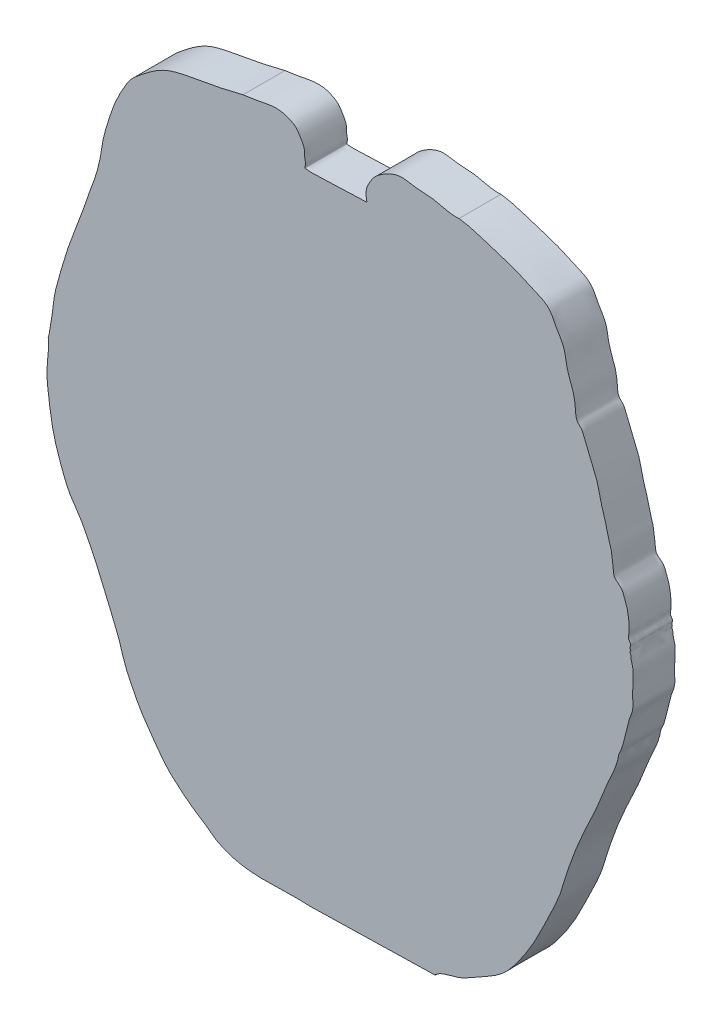
from build123d import *

# Parameters (mm, degrees)
BOSS_EXTRUDE1_DEPTH = 100


with BuildPart() as part:
    # faceplate → Boss-Extrude1 (new body)
    with BuildSketch(Plane.XY):
        with BuildLine():
            Line((-544.994463337, -612.515143976), (-544.994463337, -613.515143976))
            Line((-544.994463337, -613.515143976), (-843.994463337, -620.515143976))
            add(Edge.make_bspline(
                [(-1067.80244218, -595.323122819), (-997.118302993, -634.980800497), (-919.007086082, -615.388320094), (-843.994463337, -620.515143976)],
                knots=[0, 0, 0, 0, 1, 1, 1, 1], degree=3))
            add(Edge.make_bspline(
                [(-1067.80244218, -595.323122819), (-1086.847009226, -579.729961904), (-1119.970174816, -561.224126278), (-1156.034719167, -531.360825002), (-1179.138150383, -511.221675605), (-1196.315966942, -490.961554628), (-1213.217398231, -467.461049471), (-1232.397649452, -440.899738497), (-1252.443193652, -410.675686141), (-1269.172612691, -376.572973765), (-1286.514519484, -341.087093501), (-1296.738650953, -301.232376709), (-1313.455916177, -261.143197942), (-1331.041833976, -218.738871303), (-1349.710417714, -174.628391124), (-1370.426950686, -132.166188439), (-1390.701638967, -90.573799688), (-1419.135356979, -54.815891576), (-1435.370486427, -11.470106108), (-1451.768411171, 32.502484745), (-1461.464593921, 79.097443036), (-1467.240520327, 123.638045122), (-1472.384850807, 165.299163162), (-1468.827354686, 202.626831232), (-1466.138049197, 228.429338434), (-1468.2675659, 242.799904931), (-1465.753983266, 248.150925961), (-1464.413789059, 264.200956181), (-1457.615160207, 293.619534204), (-1454.39758417, 337.845564286), (-1438.875880143, 390.748756206), (-1421.192254415, 453.45936783), (-1394.593685546, 518.904193396), (-1375.922839318, 572.231050768), (-1364.069654655, 607.904754904), (-1355.21841365, 628.932491538), (-1349.178109577, 652.608037387), (-1341.652426333, 681.82767433), (-1338.216580607, 716.565441158), (-1327.985576082, 750.106761733), (-1318.017985391, 782.616202465), (-1306.487970813, 813.178643601), (-1292.835449403, 838.709685584), (-1281.186260324, 860.58493493), (-1266.214251902, 880.055386428), (-1236.139476743, 903.56594924), (-1193.192750352, 937.054053735), (-1128.986921291, 949.723978925), (-1077.595251561, 959.023790995), (-1036.017770222, 967.035879578), (-1015.134884478, 973.200541716), (-1003.321346267, 975.57699758)],
                knots=[0, 0, 0, 0, 0.038400577, 0.058895535, 0.073102163, 0.086227031, 0.100287806, 0.118344898, 0.137451121, 0.156851737, 0.177684982, 0.198987409, 0.220891405, 0.245488757, 0.270769139, 0.295710043, 0.319371077, 0.342894453, 0.366423959, 0.391141623, 0.416291007, 0.440510581, 0.46142581, 0.481689057, 0.498630439, 0.502576848, 0.503311323, 0.507792421, 0.527347312, 0.55072337, 0.576659082, 0.613250724, 0.652561818, 0.686915235, 0.701564699, 0.711304434, 0.722509605, 0.739687874, 0.75842357, 0.776832233, 0.794317236, 0.81162249, 0.827752702, 0.839523462, 0.850339049, 0.865807231, 0.8990697, 0.933921409, 0.965998955, 0.981184923, 1, 1, 1, 1], degree=3))
            add(Edge.make_bspline(
                [(-1003.321346267, 975.57699758), (-987.625286887, 977.252933347), (-962.704341777, 982.153446744), (-930.107996089, 988.286600947), (-907.73342782, 986.847160199), (-890.506709849, 980.153836056), (-877.228125332, 972.882171329), (-868.657722365, 960.200996549), (-862.567954839, 949.919049802), (-857.650273693, 940.261982009), (-856.6504648, 932.113160778), (-856.858442051, 925.892378776), (-856.484148597, 920.051139945), (-854.99962702, 913.576766741), (-853.805195867, 906.771565928), (-856.891801948, 896.179933995), (-849.532852724, 897.800494321), (-844.301174531, 896.09886282), (-836.051338893, 896.664214645), (-824.3827293, 897.356086054), (-811.091645754, 897.398998525), (-771.65856362, 898.71200455), (-737.566058229, 900.231134168), (-707.961414353, 901.352522194)],
                knots=[0, 0, 0, 0, 0.13240841, 0.213689757, 0.278435216, 0.316912048, 0.369102621, 0.401753187, 0.4437325, 0.470308429, 0.491738561, 0.51185491, 0.522604246, 0.541061714, 0.565961939, 0.589189548, 0.600387477, 0.616595683, 0.637287508, 0.668004499, 0.715727349, 0.748605259, 1, 1, 1, 1], degree=3))
            Line((-707.961414353, 901.352522194), (-709.994463337, 914.484856024))
            add(Edge.make_bspline(
                [(-709.994463337, 914.484856024), (-710.025141677, 928.111294219), (-706.556524679, 936.469765177), (-693.357896775, 960.709928189), (-674.711163852, 975.882524791), (-653.069107275, 988.272371826), (-626.361572185, 997.152418106), (-592.838906392, 988.511952991), (-545.459079884, 990.015587365), (-510.6758664, 975.288933631), (-488.174265844, 977.704076621)],
                knots=[0, 0, 0, 0, 0.092656003, 0.183249979, 0.277762299, 0.368010184, 0.465335235, 0.58698607, 0.749779645, 1, 1, 1, 1], degree=3))
            add(Edge.make_bspline(
                [(-488.174265844, 977.704076621), (-456.276698424, 973.772819568), (-413.082050902, 956.00139334), (-352.880537776, 940.042979017), (-315.670408772, 920.096845698), (-282.638450263, 909.115656445), (-266.103267679, 889.15808379), (-255.626909848, 864.830458522), (-234.906704646, 837.488931338), (-232.912182322, 797.596000168), (-216.805122627, 762.645190054), (-210.051739344, 729.655910292), (-210.486834721, 699.650404741), (-195.47336716, 689.870798641), (-190.356917308, 675.569305079), (-183.236172501, 660.113219275), (-175.670732081, 641.069479697), (-169.301082892, 624.944272331), (-160.940778667, 606.918509189), (-155.220160251, 586.954996915), (-150.771527302, 563.520719903), (-144.526324466, 542.958930792), (-137.322376345, 520.688253705), (-133.49244601, 498.072411215), (-124.168210293, 475.495115448), (-123.593395619, 456.007770617), (-119.600202312, 438.315780586), (-120.677701477, 423.113128801), (-108.963827659, 414.077110512), (-99.428314275, 406.758279523), (-95.092306104, 394.959107279), (-90.692706124, 383.673283845), (-86.96803427, 372.644834332), (-85.029413703, 361.089359505), (-83.067579223, 348.960606193), (-83.132833363, 337.646119686), (-81.40467488, 324.462048367), (-87.135516072, 311.967656037), (-77.007528945, 302.896484143), (-81.451175559, 296.340032763), (-78.992292255, 290.912569241), (-81.124845036, 285.38267309), (-77.850959558, 280.39504072), (-78.282792033, 272.538915116), (-75.694943087, 264.142711363), (-72.899133528, 253.136627469), (-73.345603979, 242.437648975), (-72.936069744, 230.51918813), (-74.257877633, 218.89550788), (-73.673619291, 207.232098077), (-74.800435642, 194.066808289), (-72.671127502, 179.444613631), (-75.293615575, 163.050653013), (-81.880933058, 149.176288447), (-87.222890375, 126.097374785), (-93.804330664, 101.137095727), (-100.061347869, 75.162630822), (-107.882675618, 61.861927769), (-108.797051733, 51.713845954), (-111.518705333, 42.34242457), (-115.227974273, 30.390584041), (-120.928179416, 16.556405837), (-131.70451367, -4.955944936), (-143.438372488, -34.31166144), (-156.513526554, -68.934431811), (-182.156502861, -121.832398253), (-208.666788719, -180.182076414), (-232.243947306, -246.785558045), (-247.285167827, -303.404388878), (-277.412086588, -362.677807945), (-308.293520213, -429.725258746), (-344.845724502, -485.405793139), (-387.316242531, -537.8993116), (-439.781729376, -562.908683045), (-491.433435635, -596.200471512), (-528.778610805, -598.006021791), (-544.994463337, -612.515143976)],
                knots=[0, 0, 0, 0, 0.048756592, 0.071774008, 0.095128207, 0.113854207, 0.123637851, 0.133836302, 0.154629531, 0.174655872, 0.193344689, 0.212906432, 0.227665298, 0.234662032, 0.238295876, 0.250640502, 0.260992337, 0.269730227, 0.277296236, 0.291500077, 0.301482273, 0.313949682, 0.324487113, 0.337427684, 0.349074149, 0.361675335, 0.366816306, 0.377335959, 0.382346672, 0.388579816, 0.395601081, 0.401011611, 0.407351183, 0.413396259, 0.419000859, 0.426212669, 0.430693542, 0.439508538, 0.444217573, 0.447375039, 0.449630471, 0.452774199, 0.455622726, 0.458079222, 0.464619332, 0.469002917, 0.47546356, 0.480927294, 0.487344125, 0.493373073, 0.498840054, 0.507587332, 0.515914369, 0.523898758, 0.53106219, 0.552208528, 0.563671456, 0.572002946, 0.575321816, 0.579188002, 0.586976445, 0.594554468, 0.602147984, 0.623945166, 0.643092521, 0.658999668, 0.714253083, 0.741476833, 0.767541857, 0.804019748, 0.843270655, 0.880836484, 0.906434173, 0.945574195, 0.968646857, 1, 1, 1, 1], degree=3))
        make_face()
    extrude(amount=BOSS_EXTRUDE1_DEPTH)


solid = part.part
